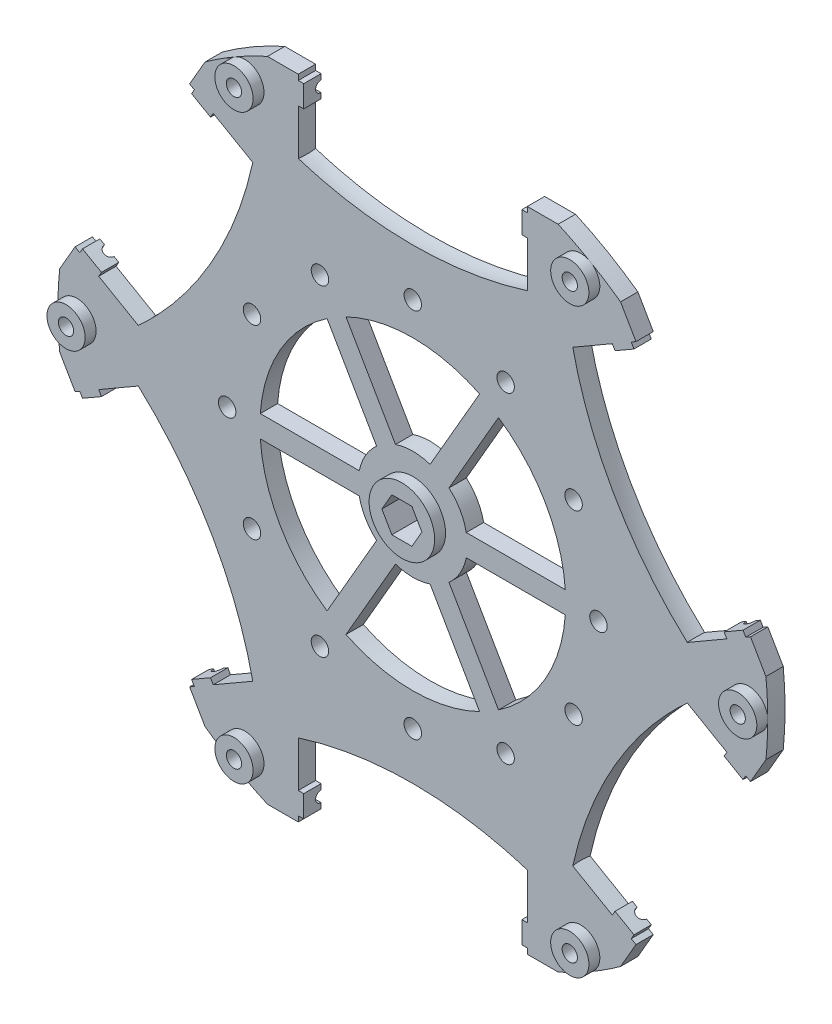
from build123d import *

# Parameters (mm, degrees)
MASTER_R                = 65
BOSS_EXTRUDE1_DEPTH     = 1.5875
SKETCH1_OUTSIDE_W       = 168.286
SKETCH1_OUTSIDE_H       = 164.809
CUT_EXTRUDE1_DEPTH      = 92.978696727
CUT_EXTRUDE1_DEPTH_BACK = 92.978696727
SKETCH4_R               = 28
SPOKES_DEPTH            = 89.000057849
SPOKES_DEPTH_BACK       = 89.000057849
BOSS_EXTRUDE5_DEPTH     = 1.5875
AXLE_R                  = 10
HUB_DEPTH               = 1.5875
HEX_AXLE_DEPTH          = 89.000057849
HEX_AXLE_DEPTH_BACK     = 89.000057849
CIRPATTERN2_COUNT       = 6
SKETCH17_W              = 1
SKETCH17_H              = 4
ROLLER_INSETS_DEPTH     = 3.175
CIRPATTERN8_COUNT       = 6
SCREW_HOLES_R           = 1.6
DISK_SPACERS_DEPTH      = 89.000057849
CIRPATTERN3_COUNT       = 12
SKETCH10_R              = 6
HUB_SPACER_INNER_DEPTH  = 2
ROLLER_AXLES_DEPTH      = 25.2
CIRPATTERN4_COUNT       = 6
SKETCH15_R              = 1.4
DISK_SCREWS_DEPTH       = 89.058844991
CIRPATTERN6_COUNT       = 6
SKETCH16_R              = 3.5
SKETCH16_R_2            = 1.4
DISK_SCREWS_BOSS_DEPTH  = 2
CIRPATTERN7_COUNT       = 6


with BuildPart() as part:
    # Master (on Front Plane) → Boss-Extrude1 (new, symmetric)
    with BuildSketch(Plane.XY):
        Circle(MASTER_R)
    extrude(amount=BOSS_EXTRUDE1_DEPTH, both=True)

    # Sketch2 → Rollers (revolve, cut)
    with BuildSketch(Plane.XY):
        with BuildLine():
            Line((-20.973647626, 56.3), (-20.973647626, 66.784025824))
            ThreePointArc((-20.973647626, 66.784025824), (0, 70), (20.973647626, 66.784025824))
            Line((20.973647626, 66.784025824), (20.973647626, 56.3))
            Line((20.973647626, 56.3), (-20.973647626, 56.3))
        make_face()
    rollers = revolve(axis=Axis((-20.973647626, 56.3, 0), (1, 0, 0)), mode=Mode.SUBTRACT)

    # Sketch1 outside → Cut-Extrude1 (cut, two sides)
    with BuildSketch(Plane.XY.offset(1.5875)) as cut_extrude1_sk:
        with Locations((0, -1.7385)):
            Rectangle(SKETCH1_OUTSIDE_W, SKETCH1_OUTSIDE_H)
        Polygon((68.473741926, 0), (34.236870963, 59.3), (-34.236870963, 59.3), (-68.473741926, 0), (-34.236870963, -59.3), (34.236870963, -59.3), align=None, mode=Mode.SUBTRACT)
    extrude(amount=CUT_EXTRUDE1_DEPTH, mode=Mode.SUBTRACT)
    extrude(cut_extrude1_sk.sketch, amount=-CUT_EXTRUDE1_DEPTH_BACK, mode=Mode.SUBTRACT)

    # Sketch4 → Spokes (cut, two sides)
    with BuildSketch(Plane.XY) as spokes_sk:
        Circle(SKETCH4_R)
    extrude(amount=SPOKES_DEPTH, mode=Mode.SUBTRACT)
    extrude(spokes_sk.sketch, amount=-SPOKES_DEPTH_BACK, mode=Mode.SUBTRACT)

    # Sketch5 → Boss-Extrude5 (add, symmetric)
    with BuildSketch(Plane.XY):
        with BuildLine():
            Line((-1.154700538, -2), (-3.464101615, -2))
            Line((-3.464101615, -2), (-15.696290851, -23.186773245))
            ThreePointArc((-15.696290851, -23.186773245), (-14, -24.248711306), (-12.232189236, -25.186773245))
            Line((-12.232189236, -25.186773245), (0, -4))
            Line((0, -4), (-1.154700538, -2))
        make_face()
        with BuildLine():
            Line((0, 4), (1.154700538, 2))
            Line((1.154700538, 2), (3.464101615, 2))
            Line((3.464101615, 2), (15.696290851, 23.186773245))
            ThreePointArc((15.696290851, 23.186773245), (14, 24.248711306), (12.232189236, 25.186773245))
            Line((12.232189236, 25.186773245), (0, 4))
        make_face()
        with BuildLine():
            Line((27.928480088, 2), (3.464101615, 2))
            Line((3.464101615, 2), (2.309401077, 0))
            Line((2.309401077, 0), (3.464101615, -2))
            Line((3.464101615, -2), (27.928480088, -2))
            ThreePointArc((27.928480088, -2), (27.982114309, -1.000639183), (28, 0))
            ThreePointArc((28, 0), (27.982114309, 1.000639183), (27.928480088, 2))
        make_face()
        with BuildLine():
            Line((3.464101615, -2), (1.154700538, -2))
            Line((1.154700538, -2), (0, -4))
            Line((0, -4), (12.232189236, -25.186773245))
            ThreePointArc((12.232189236, -25.186773245), (14, -24.248711306), (15.696290851, -23.186773245))
            Line((15.696290851, -23.186773245), (3.464101615, -2))
        make_face()
        with BuildLine():
            Line((-3.464101615, 2), (-27.928480088, 2))
            ThreePointArc((-27.928480088, 2), (-28, 0), (-27.928480088, -2))
            Line((-27.928480088, -2), (-3.464101615, -2))
            Line((-3.464101615, -2), (-2.309401077, 0))
            Line((-2.309401077, 0), (-3.464101615, 2))
        make_face()
        Polygon((-1.154700538, -2), (-2.309401077, 0), (-3.464101615, -2), align=None)
        Polygon((1.154700538, -2), (-1.154700538, -2), (0, -4), align=None)
        Polygon((3.464101615, -2), (2.309401077, 0), (1.154700538, -2), align=None)
        Polygon((3.464101615, 2), (1.154700538, 2), (2.309401077, 0), align=None)
        with BuildLine():
            Line((-15.696290851, 23.186773245), (-3.464101615, 2))
            Line((-3.464101615, 2), (-1.154700538, 2))
            Line((-1.154700538, 2), (0, 4))
            Line((0, 4), (-12.232189236, 25.186773245))
            ThreePointArc((-12.232189236, 25.186773245), (-14, 24.248711306), (-15.696290851, 23.186773245))
        make_face()
        Polygon((0, 4), (-1.154700538, 2), (1.154700538, 2), align=None)
        Polygon((-1.154700538, 2), (-3.464101615, 2), (-2.309401077, 0), align=None)
        Polygon((1.154700538, 2), (-1.154700538, 2), (-2.309401077, 0), (-1.154700538, -2), (1.154700538, -2), (2.309401077, 0), align=None)
    extrude(amount=BOSS_EXTRUDE5_DEPTH, both=True)

    # Axle → Hub (add, symmetric)
    with BuildSketch(Plane.XY):
        Circle(AXLE_R)
        Polygon((3.666174209, 0), (1.833087105, 3.175), (-1.833087105, 3.175), (-3.666174209, 0), (-1.833087105, -3.175), (1.833087105, -3.175), align=None, mode=Mode.SUBTRACT)
    extrude(amount=HUB_DEPTH, both=True)

    # Sketch9 → Hex axle (cut, two sides)
    with BuildSketch(Plane.XY) as hex_axle_sk:
        Polygon((-1.833087105, -3.175), (1.833087105, -3.175), (3.666174209, 0), (1.833087105, 3.175), (-1.833087105, 3.175), (-3.666174209, 0), align=None)
    extrude(amount=HEX_AXLE_DEPTH, mode=Mode.SUBTRACT)
    extrude(hex_axle_sk.sketch, amount=-HEX_AXLE_DEPTH_BACK, mode=Mode.SUBTRACT)

    # CirPattern2: Rollers ×6 about axis
    cirpattern2_axis = Axis((0, 0, 0), (0, 0, 1))
    for i in range(1, CIRPATTERN2_COUNT):
        add(rollers.rotate(cirpattern2_axis, i * 360 / CIRPATTERN2_COUNT), mode=Mode.SUBTRACT)

    # Sketch17 → Roller insets (add, through all)
    with BuildSketch(Plane.XY.offset(1.5875)):
        with Locations((-20.473647626, 56.3)):
            Rectangle(SKETCH17_W, SKETCH17_H)
        with Locations((20.473647626, 56.3)):
            Rectangle(SKETCH17_W, SKETCH17_H)
    roller_insets = extrude(amount=-ROLLER_INSETS_DEPTH)

    # CirPattern8: Roller insets ×6 about axis
    cirpattern8_axis = Axis((0, 0, 0), (0, 0, 1))
    for i in range(1, CIRPATTERN8_COUNT):
        add(roller_insets.rotate(cirpattern8_axis, i * 360 / CIRPATTERN8_COUNT))

    # Screw Holes (on Front Plane) → Disk spacers (cut, symmetric)
    with BuildSketch(Plane.XY):
        with Locations((34, 0)):
            Circle(SCREW_HOLES_R)
    disk_spacers = extrude(amount=DISK_SPACERS_DEPTH, both=True, mode=Mode.SUBTRACT)

    # CirPattern3: Disk spacers ×12 about axis
    cirpattern3_axis = Axis((0, 0, 0), (0, 0, 1))
    for i in range(1, CIRPATTERN3_COUNT):
        add(disk_spacers.rotate(cirpattern3_axis, i * 360 / CIRPATTERN3_COUNT), mode=Mode.SUBTRACT)

    # Sketch10 → Hub spacer inner (add)
    with BuildSketch(Plane.XY.offset(1.5875)):
        Circle(SKETCH10_R)
        Polygon((1.833087105, -3.175), (3.666174209, 0), (1.833087105, 3.175), (-1.833087105, 3.175), (-3.666174209, 0), (-1.833087105, -3.175), align=None, mode=Mode.SUBTRACT)
    extrude(amount=HUB_SPACER_INNER_DEPTH)

    # Sketch12 → Roller axles (cut, symmetric)
    with BuildSketch(Plane(origin=(0, 0, 0), x_dir=(0, 0, -1), z_dir=(1, 0, 0))):
        with BuildLine():
            Line((1.5875, 57.3), (1.5875, 55.3))
            ThreePointArc((1.5875, 55.3), (0.5875, 56.3), (1.5875, 57.3))
        make_face()
    roller_axles = extrude(amount=ROLLER_AXLES_DEPTH, both=True, mode=Mode.SUBTRACT)

    # CirPattern4: Roller axles ×6 about axis
    cirpattern4_axis = Axis((0, 0, 0), (0, 0, 1))
    for i in range(1, CIRPATTERN4_COUNT):
        add(roller_axles.rotate(cirpattern4_axis, i * 360 / CIRPATTERN4_COUNT), mode=Mode.SUBTRACT)

    # Sketch15 → Disk screws (cut, symmetric)
    with BuildSketch(Plane.XY):
        with Locations((30.75, 53.260562333)):
            Circle(SKETCH15_R)
    disk_screws = extrude(amount=DISK_SCREWS_DEPTH, both=True, mode=Mode.SUBTRACT)

    # CirPattern6: Disk screws ×6 about axis
    cirpattern6_axis = Axis((0, 0, 0), (0, 0, 1))
    for i in range(1, CIRPATTERN6_COUNT):
        add(disk_screws.rotate(cirpattern6_axis, i * 360 / CIRPATTERN6_COUNT), mode=Mode.SUBTRACT)

    # Sketch16 → Disk screws boss (add)
    with BuildSketch(Plane.XY.offset(1.5875)):
        with Locations(Location((30.75, 53.260562333, 0), (0, 0, 59.999554583))):
            Circle(SKETCH16_R)
        with Locations((30.75, 53.260562333)):
            Circle(SKETCH16_R_2, mode=Mode.SUBTRACT)
    disk_screws_boss = extrude(amount=DISK_SCREWS_BOSS_DEPTH)

    # CirPattern7: Disk screws boss ×6 about axis
    cirpattern7_axis = Axis((0, 0, 0), (0, 0, 1))
    for i in range(1, CIRPATTERN7_COUNT):
        add(disk_screws_boss.rotate(cirpattern7_axis, i * 360 / CIRPATTERN7_COUNT))


solid = part.part
